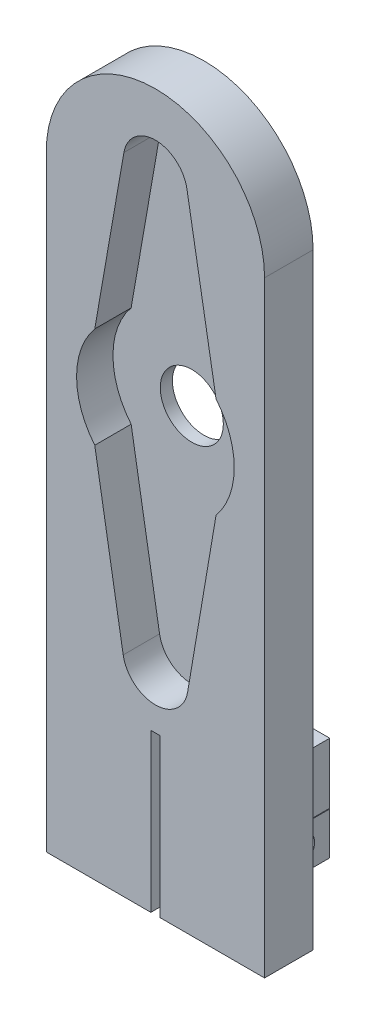
from build123d import *

# Parameters (mm, degrees)
EXTRUDE_1_DEPTH          = 4
CUT_EXTRUDE_1_DEPTH      = 3
SKETCH_4_R               = 2.6
CUT_EXTRUDE_9_DEPTH      = 19
CUT_EXTRUDE_9_DEPTH_BACK = 2
SKETCH_5_W               = 0.75
SKETCH_5_H               = 13
CUT_EXTRUDE_11_DEPTH     = 5
SKETCH_8_W               = 5
SKETCH_8_H               = 5
EXTRUDE_2_DEPTH          = 5
SKETCH_9_R               = 1.25
CUT_EXTRUDE_12_DEPTH     = 39
SKETCH_11_W              = 5
SKETCH_11_H              = 3.5
SKETCH_11_R              = 1.25
EXTRUDE_4_DEPTH          = 5


with BuildPart() as part:
    # 草圖1 → 填料-伸長1 (new body)
    with BuildSketch(Plane.XY):
        with BuildLine():
            Line((-9, 0), (-9, 50))
            ThreePointArc((-9, 50), (0, 59), (9, 50))
            Line((9, 50), (9, 0))
            Line((9, 0), (-9, 0))
        make_face()
    extrude(amount=EXTRUDE_1_DEPTH)

    # 草圖2 → 除料-伸長1 (cut)
    with BuildSketch(Plane.XY.offset(4)):
        with BuildLine():
            Line((-2.6, 53.145110573), (-5, 39.352358854))
            ThreePointArc((-5, 39.352358854), (-6.5, 35.199046922), (-5, 31.045734991))
            Line((-5, 31.045734991), (-2.656326538, 17.243300615))
            ThreePointArc((-2.656326538, 17.243300615), (0, 15), (2.656326538, 17.243300615))
            Line((2.656326538, 17.243300615), (5, 31.045734991))
            ThreePointArc((5, 31.045734991), (6.5, 35.199046922), (5, 39.352358854))
            Line((5, 39.352358854), (2.6, 53.145110573))
            ThreePointArc((2.6, 53.145110573), (0, 55.331766334), (-2.6, 53.145110573))
        make_face()
    extrude(amount=-CUT_EXTRUDE_1_DEPTH, mode=Mode.SUBTRACT)

    # 草圖4 → 除料-伸長9 (cut, two sides)
    with BuildSketch(Plane.XY) as cut_extrude_9_sk:
        with Locations((0, 34.856314216)):
            Circle(SKETCH_4_R)
    extrude(amount=CUT_EXTRUDE_9_DEPTH, mode=Mode.SUBTRACT)
    extrude(cut_extrude_9_sk.sketch, amount=-CUT_EXTRUDE_9_DEPTH_BACK, mode=Mode.SUBTRACT)

    # 草圖5 → 除料-伸長11 (cut, through all)
    with BuildSketch(Plane.XY):
        with Locations((0, 6.5)):
            Rectangle(SKETCH_5_W, SKETCH_5_H)
    extrude(amount=CUT_EXTRUDE_11_DEPTH, mode=Mode.SUBTRACT)

    # 草圖8 → 填料-伸長2 (add)
    with BuildSketch(Plane.XY):
        with Locations((2.875, 8.312164066)):
            Rectangle(SKETCH_8_W, SKETCH_8_H)
    extrude(amount=-EXTRUDE_2_DEPTH)

    # 草圖9 → 除料-伸長12 (cut)
    with BuildSketch(Plane(origin=(0, 0, 0), x_dir=(0, 0, -1), z_dir=(1, 0, 0))):
        with Locations((2.379774756, 8.312164066)):
            Circle(SKETCH_9_R)
    extrude(amount=CUT_EXTRUDE_12_DEPTH, mode=Mode.SUBTRACT)

    # 草圖11 → 填料-伸長4 (add)
    with BuildSketch(Plane(origin=(0.375, 0, 0), x_dir=(0, 0, -1), z_dir=(1, 0, 0))):
        with Locations((2.5, 4.012164066)):
            Rectangle(SKETCH_11_W, SKETCH_11_H)
        with Locations((2.5, 4.012164066)):
            Circle(SKETCH_11_R, mode=Mode.SUBTRACT)
    extrude(amount=EXTRUDE_4_DEPTH)


solid = part.part
